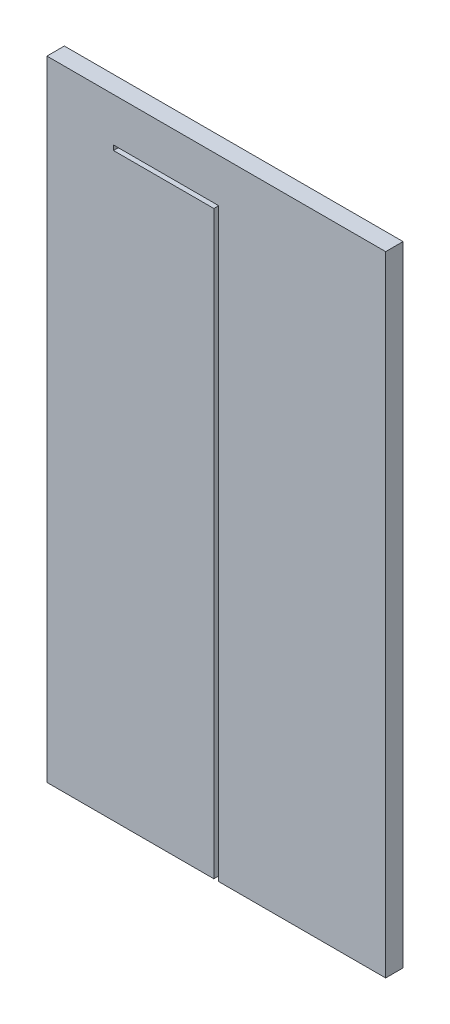
from build123d import *

# Parameters (mm, degrees)
SKICA1_W                = 350
SKICA1_H                = 650
P_IDAT_VYSUNUT_M2_DEPTH = 18


with BuildPart() as part:
    # Skica1 → Přidat vysunutím2 (new body)
    with BuildSketch(Plane.XY):
        with Locations((175, 325)):
            Rectangle(SKICA1_W, SKICA1_H)
    extrude(amount=P_IDAT_VYSUNUT_M2_DEPTH)

    # Odebrat tažením po křivce8: sweep along a path in cesta
    with BuildLine(Plane.XY.offset(18)) as odebrat_ta_en_m_po_k_ivce8_path:
        Line((175, 0), (175, 602.357194164))
        Line((175, 602.357194164), (68.787703731, 602.357194164))
    # profil na frezu → Odebrat tažením po křivce8 (sweep, cut)
    with BuildSketch(Plane.XZ):
        Polygon((190, 3), (190, 8), (177.5, 8), (177.5, 18), (172.5, 18), (172.5, 8), (160, 8), (160, 3), align=None)
    sweep(path=odebrat_ta_en_m_po_k_ivce8_path.line, transition=Transition.RIGHT, mode=Mode.SUBTRACT)


solid = part.part
